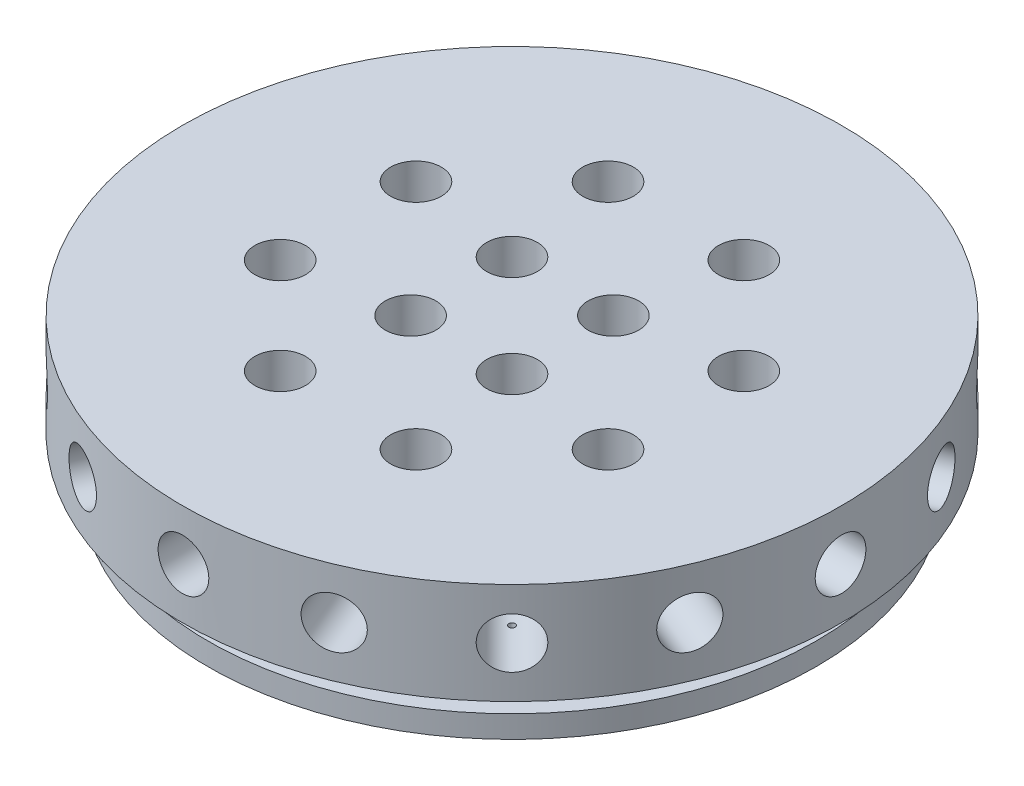
from build123d import *

# Parameters (mm, degrees)
CIRPATTERN1_COUNT                   = 16
CIRPATTERN2_COUNT                   = 8
CIRPATTERN3_COUNT                   = 4
CIRPATTERN4_COUNT                   = 4
CIRPATTERN5_COUNT                   = 8
CIRPATTERN6_COUNT                   = 16
F_1_32_0_03125_DIAMETER_HOLE3_D     = 0.79375
F_1_32_0_03125_DIAMETER_HOLE3_DEPTH = 12.7
F_1_32_0_03125_DIAMETER_HOLE3_TIP   = 0.238466558


with BuildPart() as part:
    # Sketch1 → Revolve1 (revolve)
    with BuildSketch(Plane.XY):
        Polygon((0, 0), (-38.1, 0), (-38.1, 2.78765), (-36.068, 2.78765), (-36.068, 5.55625), (-38.1, 5.55625), (-38.1, 6.35), (-41.275, 6.35), (-41.275, 19.05), (0, 19.05), align=None)
    revolve(axis=Axis((0, 19.05, 0), (0, -1, 0)))

    # Sketch13 → 1_4 _0.25_ Diameter Hole1 (revolve, cut)
    with BuildSketch(Plane(origin=(41.275, 12.7, 0), x_dir=(0, 0, -1), z_dir=(0, 1, 0))):
        Polygon((0, 0), (0, 14.607732465), (3.175, 12.7), (3.175, 0), align=None)
    f_1_4_0_25_diameter_hole1 = revolve(axis=Axis((47.625, 12.7, 0), (-1, 0, 0)), mode=Mode.SUBTRACT)

    # Sketch15 → 3_16 _0.1875_ Diameter Hole1 (revolve, cut)
    with BuildSketch(Plane(origin=(41.275, 12.7, 0), x_dir=(0, 0, -1), z_dir=(0, 1, 0))):
        Polygon((0, 0), (0, 26.830799349), (2.38125, 25.4), (2.38125, 0), align=None)
    f_3_16_0_1875_diameter_hole1 = revolve(axis=Axis((47.625, 12.7, 0), (-1, 0, 0)), mode=Mode.SUBTRACT)

    # Sketch17 → 1_8 _0.125_ Diameter Hole1 (revolve, cut)
    with BuildSketch(Plane(origin=(41.275, 12.7, 0), x_dir=(0, 0, -1), z_dir=(0, 1, 0))):
        Polygon((0, 0), (0, 35.878866233), (1.5875, 34.925), (1.5875, 0), align=None)
    f_1_8_0_125_diameter_hole1 = revolve(axis=Axis((47.625, 12.7, 0), (-1, 0, 0)), mode=Mode.SUBTRACT)

    # CirPattern1: 1_4 _0.25_ Diameter Hole1 ×16 about axis
    cirpattern1_axis = Axis((0, -42.3, 0), (0, 1, 0))
    for i in range(1, CIRPATTERN1_COUNT):
        add(f_1_4_0_25_diameter_hole1.rotate(cirpattern1_axis, i * 360 / CIRPATTERN1_COUNT), mode=Mode.SUBTRACT)

    # CirPattern2: 3_16 _0.1875_ Diameter Hole1 ×8 about axis
    cirpattern2_axis = Axis((0, -42.3, 0), (0, 1, 0))
    for i in range(1, CIRPATTERN2_COUNT):
        add(f_3_16_0_1875_diameter_hole1.rotate(cirpattern2_axis, i * 360 / CIRPATTERN2_COUNT), mode=Mode.SUBTRACT)

    # CirPattern3: 1_8 _0.125_ Diameter Hole1 ×4 about axis
    cirpattern3_axis = Axis((0, -42.3, 0), (0, 1, 0))
    for i in range(1, CIRPATTERN3_COUNT):
        add(f_1_8_0_125_diameter_hole1.rotate(cirpattern3_axis, i * 360 / CIRPATTERN3_COUNT), mode=Mode.SUBTRACT)

    # Sketch20 → inner large LOX holes (revolve, cut)
    with BuildSketch(Plane(origin=(-6.35, 19.05, 6.35), x_dir=(0, 0, 1), z_dir=(1, 0, 0))):
        Polygon((0, 0), (0, 14.607732465), (3.175, 12.7), (3.175, 0), align=None)
    inner_large_lox_holes = revolve(axis=Axis((-6.35, 25.4, 6.35), (0, -1, 0)), mode=Mode.SUBTRACT)

    # Sketch22 → outer large LOX hole (revolve, cut)
    with BuildSketch(Plane(origin=(-20.53322261, 19.05, 8.505139284), x_dir=(0, 0, 1), z_dir=(1, 0, 0))):
        Polygon((0, 0), (0, 14.607732465), (3.175, 12.7), (3.175, 0), align=None)
    outer_large_lox_hole = revolve(axis=Axis((-20.53322261, 25.4, 8.505139284), (0, -1, 0)), mode=Mode.SUBTRACT)

    # CirPattern4: inner large LOX holes ×4 about axis
    cirpattern4_axis = Axis((0, -42.3, 0), (0, 1, 0))
    for i in range(1, CIRPATTERN4_COUNT):
        add(inner_large_lox_holes.rotate(cirpattern4_axis, i * 360 / CIRPATTERN4_COUNT), mode=Mode.SUBTRACT)

    # CirPattern5: outer large LOX hole ×8 about axis
    cirpattern5_axis = Axis((0, -42.3, 0), (0, 1, 0))
    for i in range(1, CIRPATTERN5_COUNT):
        add(outer_large_lox_hole.rotate(cirpattern5_axis, i * 360 / CIRPATTERN5_COUNT), mode=Mode.SUBTRACT)

    # Sketch26 → film cooling holes (revolve, cut)
    with BuildSketch(Plane(origin=(-35.063359742, -1.581459083, 0), x_dir=(0.9961946980917455, -0.08715574274765836, 0), z_dir=(0, 0, 1))):
        Polygon((0, 0), (0, 12.938466558), (0.396875, 12.7), (0.396875, 0), align=None)
    film_cooling_holes = revolve(axis=Axis((-35.616798708, -7.907295416, 0), (0.08715574274765835, 0.9961946980917455, 0)), mode=Mode.SUBTRACT)

    # CirPattern6: film cooling holes ×16 about axis
    cirpattern6_axis = Axis((0, -42.3, 0), (0, 1, 0))
    for i in range(1, CIRPATTERN6_COUNT):
        add(film_cooling_holes.rotate(cirpattern6_axis, i * 360 / CIRPATTERN6_COUNT), mode=Mode.SUBTRACT)

    # 1_32 _0.03125_ Diameter Hole3
    with Locations(Plane.XZ):
        with Locations((-6.35, 0)):
            Hole(F_1_32_0_03125_DIAMETER_HOLE3_D / 2, depth=F_1_32_0_03125_DIAMETER_HOLE3_DEPTH)
            with Locations((0, 0, -(F_1_32_0_03125_DIAMETER_HOLE3_DEPTH + F_1_32_0_03125_DIAMETER_HOLE3_TIP / 2))):  # 118° drill point
                Cone(0, F_1_32_0_03125_DIAMETER_HOLE3_D / 2, F_1_32_0_03125_DIAMETER_HOLE3_TIP, mode=Mode.SUBTRACT)


solid = part.part
